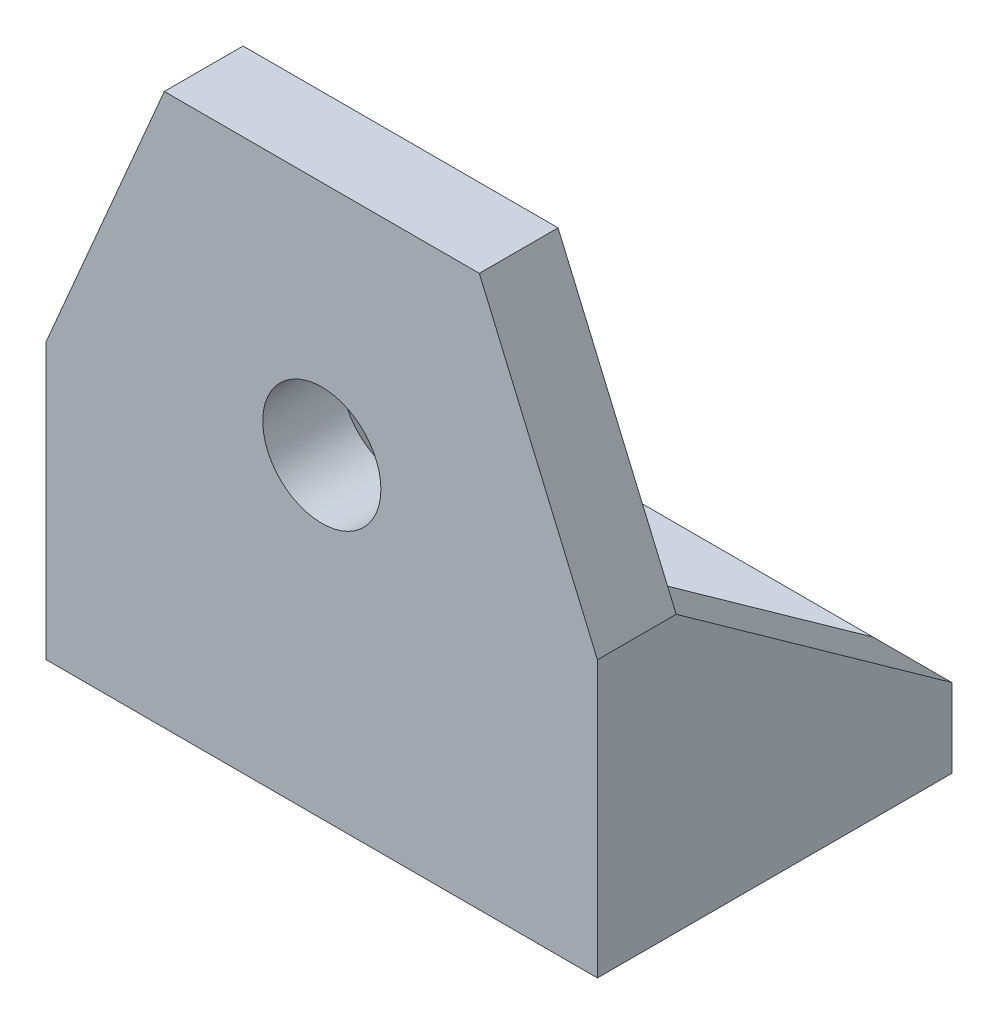
from build123d import *

# Parameters (mm, degrees)
SKETCH1_W           = 14
SKETCH1_H           = 9
BOSS_EXTRUDE1_DEPTH = 2
SKETCH2_R           = 1.25
CUT_EXTRUDE1_DEPTH  = 2
SKETCH3_W           = 14
SKETCH3_H           = 2
BOSS_EXTRUDE2_DEPTH = 12
CUT_EXTRUDE2_DEPTH  = 12
SKETCH5_W           = 2
SKETCH5_H           = 5
BOSS_EXTRUDE3_DEPTH = 7
CUT_EXTRUDE3_DEPTH  = 14
SKETCH7_R           = 1.5
CUT_EXTRUDE4_DEPTH  = 2


with BuildPart() as part:
    # Sketch1 → Boss-Extrude1 (new body)
    with BuildSketch(Plane(origin=(0, 0, 0), x_dir=(1, 0, 0), z_dir=(0, 1, 0))):
        Rectangle(SKETCH1_W, SKETCH1_H)
    extrude(amount=BOSS_EXTRUDE1_DEPTH)

    # Sketch2 → Cut-Extrude1 (cut)
    with BuildSketch(Plane(origin=(0, 2, 0), x_dir=(1, 0, 0), z_dir=(0, 1, 0))):
        with Locations((-3, 1)):
            Circle(SKETCH2_R)
        with Locations((3, 1)):
            Circle(SKETCH2_R)
    extrude(amount=-CUT_EXTRUDE1_DEPTH, mode=Mode.SUBTRACT)

    # Sketch3 → Boss-Extrude2 (add)
    with BuildSketch(Plane(origin=(0, 2, 0), x_dir=(1, 0, 0), z_dir=(0, 1, 0))):
        with Locations((0, -3.5)):
            Rectangle(SKETCH3_W, SKETCH3_H)
    extrude(amount=BOSS_EXTRUDE2_DEPTH)

    # Sketch4 → Cut-Extrude2 (cut)
    with BuildSketch(Plane.XY.offset(4.5)):
        Polygon((-7, 7), (-4, 14), (-7, 14), align=None)
        Polygon((4, 14), (7, 7), (7, 14), align=None)
    extrude(amount=-CUT_EXTRUDE2_DEPTH, mode=Mode.SUBTRACT)

    # Sketch5 → Boss-Extrude3 (add)
    with BuildSketch(Plane(origin=(0, 0, 2.5), x_dir=(-1, 0, 0), z_dir=(0, 0, -1))):
        with Locations((-6, 4.5)):
            Rectangle(SKETCH5_W, SKETCH5_H)
        with Locations((6, 4.5)):
            Rectangle(SKETCH5_W, SKETCH5_H)
    extrude(amount=BOSS_EXTRUDE3_DEPTH)

    # Sketch6 → Cut-Extrude3 (cut)
    with BuildSketch(Plane(origin=(7, 0, 0), x_dir=(0, 0, -1), z_dir=(1, 0, 0))):
        Polygon((-2.5, 7), (4.5, 2), (4.5, 7), align=None)
    extrude(amount=-CUT_EXTRUDE3_DEPTH, mode=Mode.SUBTRACT)

    # Sketch7 → Cut-Extrude4 (cut)
    with BuildSketch(Plane.XY.offset(4.5)):
        with Locations((0, 8)):
            Circle(SKETCH7_R)
    extrude(amount=-CUT_EXTRUDE4_DEPTH, mode=Mode.SUBTRACT)


solid = part.part
